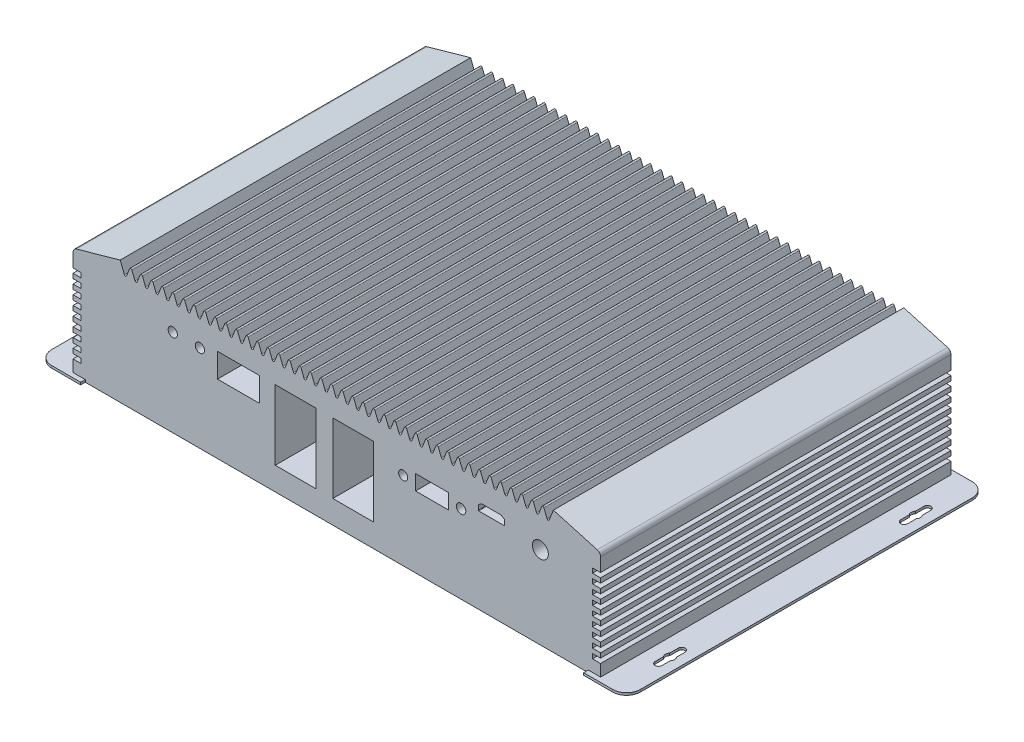
from build123d import *

# Parameters (mm, degrees)
EXTRUDE_1_DEPTH     = 155.2
CUT_EXTRUDE_1_DEPTH = 2
CUT_EXTRUDE_2_DEPTH = 2
EXTRUDE_2_DEPTH     = 151.2
FILLET_1_R          = 0.5
SKETCH_6_R          = 2
SKETCH_6_R_2        = 3.45
SKETCH_6_R_3        = 1.944774677
SKETCH_6_R_4        = 2.033756455
SKETCH_6_W          = 18.23
SKETCH_6_H          = 10.4
SKETCH_6_W_2        = 14.212845153
SKETCH_6_H_2        = 6.520451098
SKETCH_6_W_3        = 17.505801366
SKETCH_6_H_3        = 30.130762687
SKETCH_6_W_4        = 17.505801363
SKETCH_6_H_4        = 30.13076256
CUT_EXTRUDE_3_DEPTH = 20
SKETCH_7_W          = 38.122304269
SKETCH_7_H          = 12.094597331
SKETCH_7_W_2        = 14.63
SKETCH_7_H_2        = 29.59
SKETCH_7_W_3        = 13.861133126
SKETCH_7_H_3        = 15.038111323
SKETCH_7_W_4        = 38.122304268
SKETCH_7_H_4        = 12.094597332
CUT_EXTRUDE_4_DEPTH = 20


with BuildPart() as part:
    # 草图1 → 凸台-拉伸1 (new body)
    with BuildSketch(Plane.XY):
        with BuildLine():
            Line((-108.53, 42.3), (-108.53, 0.5))
            Line((-108.53, 0.5), (0, 0.5))
            Line((0, 0.5), (0, 46.5))
            Line((0, 46.5), (-104.33, 46.5))
            ThreePointArc((-104.33, 46.5), (-107.299848481, 45.269848481), (-108.53, 42.3))
        make_face()
        with BuildLine():
            Line((0, 46.5), (0, 0.5))
            Line((0, 0.5), (108.53, 0.5))
            Line((108.53, 0.5), (108.53, 42.3))
            ThreePointArc((108.53, 42.3), (107.299848481, 45.269848481), (104.33, 46.5))
            Line((104.33, 46.5), (0, 46.5))
        make_face()
        Polygon((-108.53, 0.5), (-127.01, 0.5), (-127.01, -0.5), (127.01, -0.5), (127.01, 0.5), (108.53, 0.5), (0, 0.5), align=None)
    extrude(amount=-EXTRUDE_1_DEPTH)

    # 草图2 → 切除-拉伸1 (cut)
    with BuildSketch(Plane.XY):
        with BuildLine():
            Line((104.33, 46.5), (-104.33, 46.5))
            ThreePointArc((-104.33, 46.5), (-107.299848481, 45.269848481), (-108.53, 42.3))
            Line((-108.53, 42.3), (-108.53, 0.5))
            Line((-108.53, 0.5), (-108.53, -0.5))
            Line((-108.53, -0.5), (108.53, -0.5))
            Line((108.53, -0.5), (108.53, 0.5))
            Line((108.53, 0.5), (108.53, 42.3))
            ThreePointArc((108.53, 42.3), (107.299848481, 45.269848481), (104.33, 46.5))
        make_face()
    cut_extrude_1 = extrude(amount=-CUT_EXTRUDE_1_DEPTH, mode=Mode.SUBTRACT)

    # 镜向1: 切除-拉伸1 across plane
    add(cut_extrude_1.mirror(Plane.XY.offset(-77.6)), mode=Mode.SUBTRACT)

    # 草图3 → 切除-拉伸2 (cut)
    with BuildSketch(Plane.XZ.offset(0.5)):
        with BuildLine():
            Line((-119.745, -23.277124344), (-119.745, -19.6))
            ThreePointArc((-119.745, -19.6), (-121.245, -18.1), (-122.745, -19.6))
            Line((-122.745, -19.6), (-122.745, -23.277124344))
            ThreePointArc((-122.745, -23.277124344), (-123.245, -24.6), (-122.745, -25.922875656))
            Line((-122.745, -25.922875656), (-122.745, -29.6))
            ThreePointArc((-122.745, -29.6), (-121.245, -31.1), (-119.745, -29.6))
            Line((-119.745, -29.6), (-119.745, -25.922875656))
            ThreePointArc((-119.745, -25.922875656), (-119.245, -24.6), (-119.745, -23.277124344))
        make_face()
        with BuildLine():
            ThreePointArc((-127.01, -6), (-125.252640687, -1.757359313), (-121.01, 0))
            Line((-121.01, 0), (-127.01, 0))
            Line((-127.01, 0), (-127.01, -6))
        make_face()
        with BuildLine():
            Line((127.01, 0), (121.01, 0))
            ThreePointArc((121.01, 0), (125.252640687, -1.757359313), (127.01, -6))
            Line((127.01, -6), (127.01, 0))
        make_face()
        with BuildLine():
            ThreePointArc((-121.01, -155.2), (-125.252640687, -153.442640687), (-127.01, -149.2))
            Line((-127.01, -149.2), (-127.01, -155.2))
            Line((-127.01, -155.2), (-121.01, -155.2))
        make_face()
        with BuildLine():
            Line((127.01, -155.2), (127.01, -149.2))
            ThreePointArc((127.01, -149.2), (125.252640687, -153.442640687), (121.01, -155.2))
            Line((121.01, -155.2), (127.01, -155.2))
        make_face()
        with BuildLine():
            ThreePointArc((-122.745, -135.6), (-121.245, -137.1), (-119.745, -135.6))
            Line((-119.745, -135.6), (-119.745, -131.922875656))
            ThreePointArc((-119.745, -131.922875656), (-119.245, -130.6), (-119.745, -129.277124344))
            Line((-119.745, -129.277124344), (-119.745, -125.6))
            ThreePointArc((-119.745, -125.6), (-121.245, -124.1), (-122.745, -125.6))
            Line((-122.745, -125.6), (-122.745, -129.277124344))
            ThreePointArc((-122.745, -129.277124344), (-123.245, -130.6), (-122.745, -131.922875656))
            Line((-122.745, -131.922875656), (-122.745, -135.6))
        make_face()
        with BuildLine():
            Line((119.745, -131.922875656), (119.745, -135.6))
            ThreePointArc((119.745, -135.6), (121.245, -137.1), (122.745, -135.6))
            Line((122.745, -135.6), (122.745, -131.922875656))
            ThreePointArc((122.745, -131.922875656), (123.245, -130.6), (122.745, -129.277124344))
            Line((122.745, -129.277124344), (122.745, -125.6))
            ThreePointArc((122.745, -125.6), (121.245, -124.1), (119.745, -125.6))
            Line((119.745, -125.6), (119.745, -129.277124344))
            ThreePointArc((119.745, -129.277124344), (119.245, -130.6), (119.745, -131.922875656))
        make_face()
        with BuildLine():
            ThreePointArc((122.745, -19.6), (121.245, -18.1), (119.745, -19.6))
            Line((119.745, -19.6), (119.745, -23.277124344))
            ThreePointArc((119.745, -23.277124344), (119.245, -24.6), (119.745, -25.922875656))
            Line((119.745, -25.922875656), (119.745, -29.6))
            ThreePointArc((119.745, -29.6), (121.245, -31.1), (122.745, -29.6))
            Line((122.745, -29.6), (122.745, -25.922875656))
            ThreePointArc((122.745, -25.922875656), (123.245, -24.6), (122.745, -23.277124344))
            Line((122.745, -23.277124344), (122.745, -19.6))
        make_face()
    extrude(amount=-CUT_EXTRUDE_2_DEPTH, mode=Mode.SUBTRACT)

    # 草图5 → 凸台-拉伸2 (add)
    with BuildSketch(Plane.XY.offset(-2)):
        with BuildLine():
            Line((-113.815, -0.5), (-108.53, -0.5))
            Line((-108.53, -0.5), (-108.53, 0.5))
            Line((-108.53, 0.5), (-108.53, 42.3))
            ThreePointArc((-108.53, 42.3), (-107.299848481, 45.269848481), (-104.33, 46.5))
            Line((-104.33, 46.5), (0, 46.5))
            Line((0, 46.5), (0, 46.97))
            Line((0, 46.97), (-1.796884058, 51.546258531))
            ThreePointArc((-1.796884058, 51.546258531), (-2.260620731, 51.863511649), (-2.726467952, 51.549365809))
            Line((-2.726467952, 51.549365809), (-4.091289835, 48.140634191))
            ThreePointArc((-4.091289835, 48.140634191), (-4.557137056, 47.826488351), (-5.020873729, 48.143741469))
            Line((-5.020873729, 48.143741469), (-6.356884058, 51.546258531))
            ThreePointArc((-6.356884058, 51.546258531), (-6.820620731, 51.863511649), (-7.286467952, 51.549365809))
            Line((-7.286467952, 51.549365809), (-8.651289835, 48.140634191))
            ThreePointArc((-8.651289835, 48.140634191), (-9.117137056, 47.826488351), (-9.580873729, 48.143741469))
            Line((-9.580873729, 48.143741469), (-10.916884058, 51.546258531))
            ThreePointArc((-10.916884058, 51.546258531), (-11.380620731, 51.863511649), (-11.846467952, 51.549365809))
            Line((-11.846467952, 51.549365809), (-13.211289835, 48.140634191))
            ThreePointArc((-13.211289835, 48.140634191), (-13.677137056, 47.826488351), (-14.140873729, 48.143741469))
            Line((-14.140873729, 48.143741469), (-15.476884058, 51.546258531))
            ThreePointArc((-15.476884058, 51.546258531), (-15.940620731, 51.863511649), (-16.406467952, 51.549365809))
            Line((-16.406467952, 51.549365809), (-17.771289835, 48.140634191))
            ThreePointArc((-17.771289835, 48.140634191), (-18.237137056, 47.826488351), (-18.700873729, 48.143741469))
            Line((-18.700873729, 48.143741469), (-20.036884058, 51.546258531))
            ThreePointArc((-20.036884058, 51.546258531), (-20.500620731, 51.863511649), (-20.966467952, 51.549365809))
            Line((-20.966467952, 51.549365809), (-22.331289835, 48.140634191))
            ThreePointArc((-22.331289835, 48.140634191), (-22.797137056, 47.826488351), (-23.260873729, 48.143741469))
            Line((-23.260873729, 48.143741469), (-24.596884058, 51.546258531))
            ThreePointArc((-24.596884058, 51.546258531), (-25.060620731, 51.863511649), (-25.526467952, 51.549365809))
            Line((-25.526467952, 51.549365809), (-26.891289835, 48.140634191))
            ThreePointArc((-26.891289835, 48.140634191), (-27.357137056, 47.826488351), (-27.820873729, 48.143741469))
            Line((-27.820873729, 48.143741469), (-29.156884058, 51.546258531))
            ThreePointArc((-29.156884058, 51.546258531), (-29.620620731, 51.863511649), (-30.086467952, 51.549365809))
            Line((-30.086467952, 51.549365809), (-31.451289835, 48.140634191))
            ThreePointArc((-31.451289835, 48.140634191), (-31.917137056, 47.826488351), (-32.380873729, 48.143741469))
            Line((-32.380873729, 48.143741469), (-33.716884058, 51.546258531))
            ThreePointArc((-33.716884058, 51.546258531), (-34.180620731, 51.863511649), (-34.646467952, 51.549365809))
            Line((-34.646467952, 51.549365809), (-36.011289835, 48.140634191))
            ThreePointArc((-36.011289835, 48.140634191), (-36.477137056, 47.826488351), (-36.940873729, 48.143741469))
            Line((-36.940873729, 48.143741469), (-38.276884058, 51.546258531))
            ThreePointArc((-38.276884058, 51.546258531), (-38.740620731, 51.863511649), (-39.206467952, 51.549365809))
            Line((-39.206467952, 51.549365809), (-40.571289835, 48.140634191))
            ThreePointArc((-40.571289835, 48.140634191), (-41.037137056, 47.826488351), (-41.500873729, 48.143741469))
            Line((-41.500873729, 48.143741469), (-42.836884058, 51.546258531))
            ThreePointArc((-42.836884058, 51.546258531), (-43.300620731, 51.863511649), (-43.766467952, 51.549365809))
            Line((-43.766467952, 51.549365809), (-45.131289835, 48.140634191))
            ThreePointArc((-45.131289835, 48.140634191), (-45.597137056, 47.826488351), (-46.060873729, 48.143741469))
            Line((-46.060873729, 48.143741469), (-47.396884058, 51.546258531))
            ThreePointArc((-47.396884058, 51.546258531), (-47.860620731, 51.863511649), (-48.326467952, 51.549365809))
            Line((-48.326467952, 51.549365809), (-49.691289835, 48.140634191))
            ThreePointArc((-49.691289835, 48.140634191), (-50.157137056, 47.826488351), (-50.620873729, 48.143741469))
            Line((-50.620873729, 48.143741469), (-51.956884058, 51.546258531))
            ThreePointArc((-51.956884058, 51.546258531), (-52.420620731, 51.863511649), (-52.886467952, 51.549365809))
            Line((-52.886467952, 51.549365809), (-54.251289835, 48.140634191))
            ThreePointArc((-54.251289835, 48.140634191), (-54.717137056, 47.826488351), (-55.180873729, 48.143741469))
            Line((-55.180873729, 48.143741469), (-56.516884058, 51.546258531))
            ThreePointArc((-56.516884058, 51.546258531), (-56.980620731, 51.863511649), (-57.446467952, 51.549365809))
            Line((-57.446467952, 51.549365809), (-58.811289835, 48.140634191))
            ThreePointArc((-58.811289835, 48.140634191), (-59.277137056, 47.826488351), (-59.740873729, 48.143741469))
            Line((-59.740873729, 48.143741469), (-61.076884058, 51.546258531))
            ThreePointArc((-61.076884058, 51.546258531), (-61.540620731, 51.863511649), (-62.006467952, 51.549365809))
            Line((-62.006467952, 51.549365809), (-63.371289835, 48.140634191))
            ThreePointArc((-63.371289835, 48.140634191), (-63.837137056, 47.826488351), (-64.300873729, 48.143741469))
            Line((-64.300873729, 48.143741469), (-65.636884058, 51.546258531))
            ThreePointArc((-65.636884058, 51.546258531), (-66.100620731, 51.863511649), (-66.566467952, 51.549365809))
            Line((-66.566467952, 51.549365809), (-67.931289835, 48.140634191))
            ThreePointArc((-67.931289835, 48.140634191), (-68.397137056, 47.826488351), (-68.860873729, 48.143741469))
            Line((-68.860873729, 48.143741469), (-70.196884058, 51.546258531))
            ThreePointArc((-70.196884058, 51.546258531), (-70.660620731, 51.863511649), (-71.126467952, 51.549365809))
            Line((-71.126467952, 51.549365809), (-72.491289835, 48.140634191))
            ThreePointArc((-72.491289835, 48.140634191), (-72.957137056, 47.826488351), (-73.420873729, 48.143741469))
            Line((-73.420873729, 48.143741469), (-74.756884058, 51.546258531))
            ThreePointArc((-74.756884058, 51.546258531), (-75.220620731, 51.863511649), (-75.686467952, 51.549365809))
            Line((-75.686467952, 51.549365809), (-77.051289835, 48.140634191))
            ThreePointArc((-77.051289835, 48.140634191), (-77.517137056, 47.826488351), (-77.980873729, 48.143741469))
            Line((-77.980873729, 48.143741469), (-79.316884058, 51.546258531))
            ThreePointArc((-79.316884058, 51.546258531), (-79.780620731, 51.863511649), (-80.246467952, 51.549365809))
            Line((-80.246467952, 51.549365809), (-81.611289835, 48.140634191))
            ThreePointArc((-81.611289835, 48.140634191), (-82.077137056, 47.826488351), (-82.540873729, 48.143741469))
            Line((-82.540873729, 48.143741469), (-83.876884058, 51.546258531))
            ThreePointArc((-83.876884058, 51.546258531), (-84.340620731, 51.863511649), (-84.806467952, 51.549365809))
            Line((-84.806467952, 51.549365809), (-86.171289835, 48.140634191))
            ThreePointArc((-86.171289835, 48.140634191), (-86.637137056, 47.826488351), (-87.100873729, 48.143741469))
            Line((-87.100873729, 48.143741469), (-88.436884058, 51.546258531))
            ThreePointArc((-88.436884058, 51.546258531), (-88.900620731, 51.863511649), (-89.366467952, 51.549365809))
            Line((-89.366467952, 51.549365809), (-90.731289835, 48.140634191))
            ThreePointArc((-90.731289835, 48.140634191), (-91.197137056, 47.826488351), (-91.660873729, 48.143741469))
            Line((-91.660873729, 48.143741469), (-93.457757787, 52.72))
            Line((-93.457757787, 52.72), (-112.358639642, 47.381355918))
            ThreePointArc((-112.358639642, 47.381355918), (-113.409879193, 46.663457157), (-113.815, 45.456659594))
            Line((-113.815, 45.456659594), (-113.815, 39.578137816))
            Line((-113.815, 39.578137816), (-110.315, 39.578137816))
            Line((-110.315, 39.578137816), (-110.315, 37.578137816))
            Line((-110.315, 37.578137816), (-113.815, 37.578137816))
            Line((-113.815, 37.578137816), (-113.815, 35.578137816))
            Line((-113.815, 35.578137816), (-110.315, 35.578137816))
            Line((-110.315, 35.578137816), (-110.315, 33.578137816))
            Line((-110.315, 33.578137816), (-113.815, 33.578137816))
            Line((-113.815, 33.578137816), (-113.815, 31.578137816))
            Line((-113.815, 31.578137816), (-110.315, 31.578137816))
            Line((-110.315, 31.578137816), (-110.315, 29.578137816))
            Line((-110.315, 29.578137816), (-113.815, 29.578137816))
            Line((-113.815, 29.578137816), (-113.815, 27.578137816))
            Line((-113.815, 27.578137816), (-110.315, 27.578137816))
            Line((-110.315, 27.578137816), (-110.315, 25.578137816))
            Line((-110.315, 25.578137816), (-113.815, 25.578137816))
            Line((-113.815, 25.578137816), (-113.815, 23.578137816))
            Line((-113.815, 23.578137816), (-110.315, 23.578137816))
            Line((-110.315, 23.578137816), (-110.315, 21.578137816))
            Line((-110.315, 21.578137816), (-113.815, 21.578137816))
            Line((-113.815, 21.578137816), (-113.815, 19.578137816))
            Line((-113.815, 19.578137816), (-110.315, 19.578137816))
            Line((-110.315, 19.578137816), (-110.315, 17.578137816))
            Line((-110.315, 17.578137816), (-113.815, 17.578137816))
            Line((-113.815, 17.578137816), (-113.815, 15.578137816))
            Line((-113.815, 15.578137816), (-110.315, 15.578137816))
            Line((-110.315, 15.578137816), (-110.315, 13.578137816))
            Line((-110.315, 13.578137816), (-113.815, 13.578137816))
            Line((-113.815, 13.578137816), (-113.815, 11.578137816))
            Line((-113.815, 11.578137816), (-110.315, 11.578137816))
            Line((-110.315, 11.578137816), (-110.315, 9.578137816))
            Line((-110.315, 9.578137816), (-113.815, 9.578137816))
            Line((-113.815, 9.578137816), (-113.815, 7.578137816))
            Line((-113.815, 7.578137816), (-110.315, 7.578137816))
            Line((-110.315, 7.578137816), (-110.315, 5.578137816))
            Line((-110.315, 5.578137816), (-113.815, 5.578137816))
            Line((-113.815, 5.578137816), (-113.815, -0.5))
        make_face()
    extrude_2 = extrude(amount=-EXTRUDE_2_DEPTH)

    # 镜向2: 凸台-拉伸2 across plane
    add(extrude_2.mirror(Plane(origin=(0, 0, 0), x_dir=(0, 0, 1), z_dir=(1, 0, 0))))

    # 圆角1
    fillet_1_edges = [part.edges().sort_by_distance(p)[0] for p in [
        (0, 46.97, -77.6),
    ]]
    fillet(fillet_1_edges, radius=FILLET_1_R)

    # 草图6 → 切除-拉伸3 (cut)
    with BuildSketch(Plane.XY.offset(-2)):
        with Locations((-70.780503237, 37.105582861)):
            Circle(SKETCH_6_R)
        with Locations((-59.080503237, 37.105582861)):
            Circle(SKETCH_6_R)
        with Locations((87.835274493, 35.105582824)):
            Circle(SKETCH_6_R_2)
        with Locations((28.630939146, 33.330582824)):
            Circle(SKETCH_6_R_3)
        with Locations((53.630939146, 33.330582824)):
            Circle(SKETCH_6_R_4)
        with Locations((-42.36344284, 34.405582824)):
            Rectangle(SKETCH_6_W, SKETCH_6_H)
        with BuildLine():
            Line((72.353850293, 38.664956131), (70.993295165, 39.571992883))
            ThreePointArc((70.993295165, 39.571992883), (70.940311956, 39.597001229), (70.882355126, 39.605582824))
            Line((70.882355126, 39.605582824), (62.603465381, 39.605582824))
            ThreePointArc((62.603465381, 39.605582824), (62.545508551, 39.597001229), (62.492525342, 39.571992883))
            Line((62.492525342, 39.571992883), (61.131970214, 38.664956131))
            ThreePointArc((61.131970214, 38.664956131), (61.066575334, 38.592917657), (61.042910254, 38.498546072))
            Line((61.042910254, 38.498546072), (61.042910254, 36.505582824))
            ThreePointArc((61.042910254, 36.505582824), (61.101488897, 36.364161468), (61.242910254, 36.305582824))
            Line((61.242910254, 36.305582824), (72.242910254, 36.305582824))
            ThreePointArc((72.242910254, 36.305582824), (72.38433161, 36.364161468), (72.442910254, 36.505582824))
            Line((72.442910254, 36.505582824), (72.442910254, 38.498546072))
            ThreePointArc((72.442910254, 38.498546072), (72.419245173, 38.592917657), (72.353850293, 38.664956131))
        make_face()
        with Locations((41.095400052, 33.393897397)):
            Rectangle(SKETCH_6_W_2, SKETCH_6_H_2)
        with Locations((-17.809767687, 24.540201475)):
            Rectangle(SKETCH_6_W_3, SKETCH_6_H_3)
        with Locations((7.034430949, 24.540201543)):
            Rectangle(SKETCH_6_W_4, SKETCH_6_H_4)
    extrude(amount=-CUT_EXTRUDE_3_DEPTH, mode=Mode.SUBTRACT)

    # 草图7 → 切除-拉伸4 (cut)
    with BuildSketch(Plane(origin=(0, 0, -153.2), x_dir=(-1, 0, 0), z_dir=(0, 0, -1))):
        with Locations((-27.52922844, 12.295321249)):
            Rectangle(SKETCH_7_W, SKETCH_7_H)
        with Locations((-82.065115984, 26.628533396)):
            Rectangle(SKETCH_7_W_2, SKETCH_7_H_2)
        with Locations((-61.057517231, 33.904477735)):
            Rectangle(SKETCH_7_W_3, SKETCH_7_H_3)
        with Locations((-27.530410527, 35.376234731)):
            Rectangle(SKETCH_7_W, SKETCH_7_H)
        with Locations((17.494325209, 12.361882881)):
            Rectangle(SKETCH_7_W_4, SKETCH_7_H)
        with Locations((17.493143122, 35.442796363)):
            Rectangle(SKETCH_7_W_4, SKETCH_7_H)
        with Locations((62.375497828, 12.311477844)):
            Rectangle(SKETCH_7_W_4, SKETCH_7_H)
        with Locations((62.374315741, 35.392391326)):
            Rectangle(SKETCH_7_W_4, SKETCH_7_H_4)
    extrude(amount=-CUT_EXTRUDE_4_DEPTH, mode=Mode.SUBTRACT)


solid = part.part
